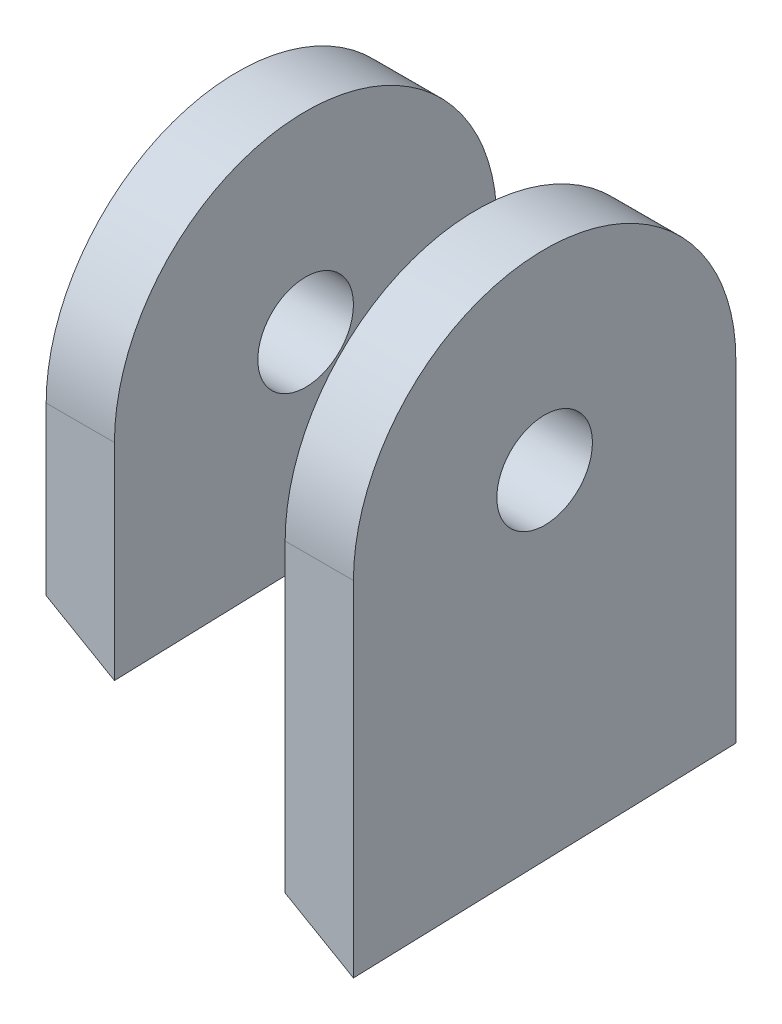
from build123d import *

# Parameters (mm, degrees)
EXTRUDE_1_DEPTH      = 10
EXTRUDE_1_DEPTH_BACK = 35
SKETCH_1_R           = 7
CUT_EXTRUDE_START    = -25
SKETCH_1_2_R         = 7
CUT_EXTRUDE_1_DEPTH  = 25
SKETCH_2_R           = 145.556166069
CUT_EXTRUDE_5_DEPTH  = 168


with BuildPart() as part:
    # 草图1 → 凸台-拉伸1 (new, two sides: drawn at the far end of the back side and taken through both)
    with BuildSketch(Plane(origin=(0, 0, 0), x_dir=(0, 0, -1), z_dir=(1, 0, 0)).offset(-EXTRUDE_1_DEPTH_BACK)):
        with BuildLine():
            Line((-28, 0), (-28, -100))
            Line((-28, -100), (28, -100))
            Line((28, -100), (28, 0))
            ThreePointArc((28, 0), (0, 28), (-28, 0))
        make_face()
        Circle(SKETCH_1_R, mode=Mode.SUBTRACT)
    extrude(amount=EXTRUDE_1_DEPTH + EXTRUDE_1_DEPTH_BACK)

    # 草图1<2> → 切除-拉伸1 (cut)
    with BuildSketch(Plane(origin=(0, 0, 0), x_dir=(0, 0, -1), z_dir=(1, 0, 0)).offset(CUT_EXTRUDE_START)):
        with BuildLine():
            Line((-28, 0), (-28, -100))
            Line((-28, -100), (28, -100))
            Line((28, -100), (28, 0))
            ThreePointArc((28, 0), (0, 28), (-28, 0))
        make_face()
        Circle(SKETCH_1_2_R, mode=Mode.SUBTRACT)
    extrude(amount=CUT_EXTRUDE_1_DEPTH, mode=Mode.SUBTRACT)


with BuildPart() as cut_extrude_1_piece_1:
    # of the separate pieces the step leaves, piece 1, a body of its own (cut_extrude_1_pieces)
    add(part.part.solids().sort_by_distance((10, 0, 28))[0])


with BuildPart() as cut_extrude_1_piece_2:
    # of the separate pieces the step leaves, piece 2, a body of its own (cut_extrude_1_pieces)
    add(part.part.solids().sort_by_distance((-25, 0, 28))[0])


with BuildPart() as cut_extrude_5_tool:
    # 草图2 → 切除-拉伸5 (new body)
    with BuildSketch(Plane(origin=(-18.933890419, -32.777900255, -1.04205282), x_dir=(-0.7521898804506026, 0.41831008991821805, 0.5091434497470438), z_dir=(0.49999999999999845, 0.8655880944028659, 0.027518190856543806))):
        Circle(SKETCH_2_R)
    extrude(amount=-CUT_EXTRUDE_5_DEPTH)


with BuildPart() as cut_extrude_1_piece_1_1:
    add(cut_extrude_1_piece_1.part)

    # 切除-拉伸5: cut by cut_extrude_5_tool
    add(cut_extrude_5_tool.part, mode=Mode.SUBTRACT)


with BuildPart() as cut_extrude_1_piece_2_1:
    add(cut_extrude_1_piece_2.part)

    # 切除-拉伸5: cut by cut_extrude_5_tool
    add(cut_extrude_5_tool.part, mode=Mode.SUBTRACT)


solid = Compound([cut_extrude_1_piece_1_1.part, cut_extrude_1_piece_2_1.part])
